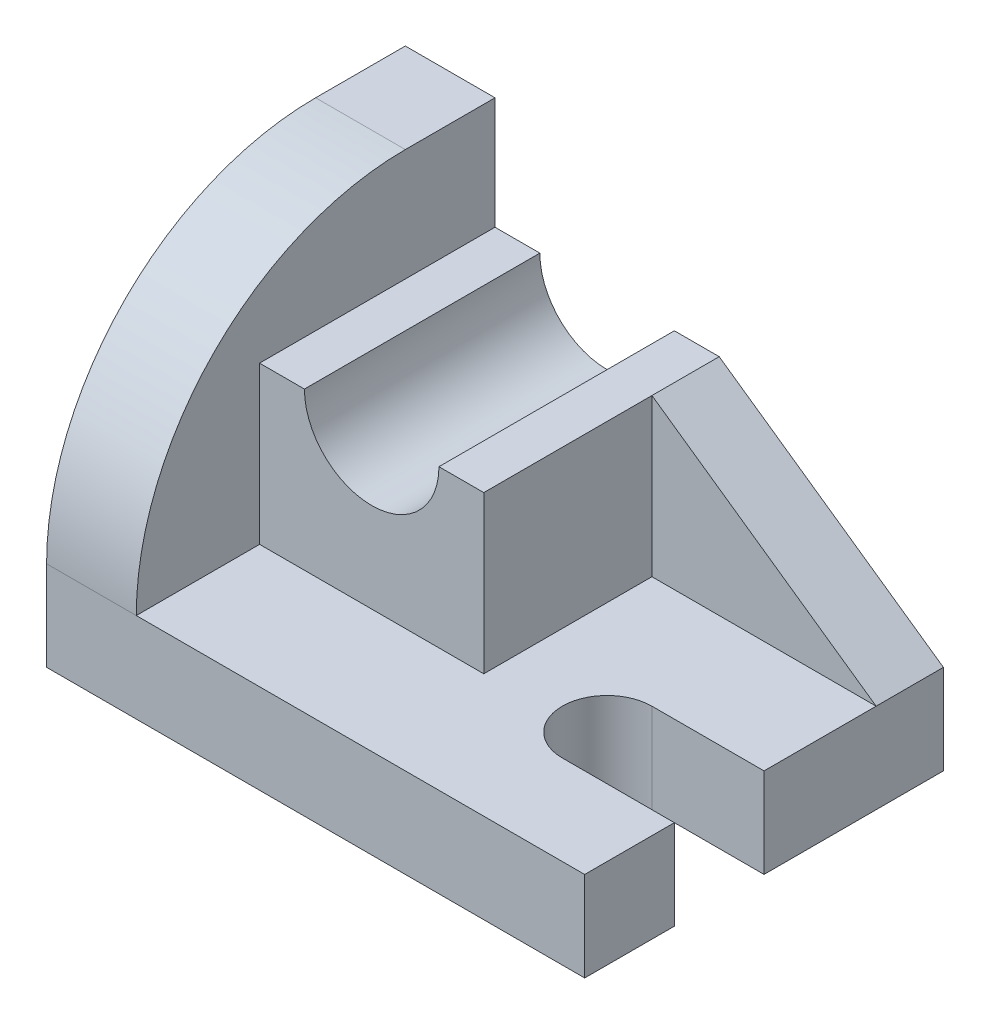
from build123d import *

# Parameters (mm, degrees)
SKETCH1_W           = 96
SKETCH1_H           = 64
BOSS_EXTRUDE1_DEPTH = 16
CUT_EXTRUDE1_DEPTH  = 16
BOSS_EXTRUDE2_DEPTH = 16
SKETCH4_W           = 40
SKETCH4_H           = 42
BOSS_EXTRUDE3_DEPTH = 28
CUT_EXTRUDE2_REACH  = 44
SKETCH5_R           = 12
BOSS_EXTRUDE4_DEPTH = 12


with BuildPart() as part:
    # Sketch1 → Boss-Extrude1 (new body)
    with BuildSketch(Plane(origin=(0, 0, 0), x_dir=(1, 0, 0), z_dir=(0, 1, 0))):
        with Locations((48, 32)):
            Rectangle(SKETCH1_W, SKETCH1_H)
    extrude(amount=BOSS_EXTRUDE1_DEPTH)

    # Sketch2 → Cut-Extrude1 (cut)
    with BuildSketch(Plane(origin=(0, 16, 0), x_dir=(1, 0, 0), z_dir=(0, 1, 0))):
        with BuildLine():
            Line((96, 16), (76, 16))
            ThreePointArc((76, 16), (68, 24), (76, 32))
            Line((76, 32), (96, 32))
            ThreePointArc((96, 32), (104, 24), (96, 16))
        make_face()
    extrude(amount=-CUT_EXTRUDE1_DEPTH, mode=Mode.SUBTRACT)

    # Sketch3 → Boss-Extrude2 (add)
    with BuildSketch(Plane.ZY):
        with BuildLine():
            Line((-64, 0), (0, 0))
            Line((0, 0), (0, 16))
            ThreePointArc((0, 16), (-14.058874503, 49.941125497), (-48, 64))
            Line((-48, 64), (-64, 64))
            Line((-64, 64), (-64, 0))
        make_face()
    extrude(amount=-BOSS_EXTRUDE2_DEPTH)

    # Sketch4 → Boss-Extrude3 (add)
    with BuildSketch(Plane(origin=(0, 16, 0), x_dir=(1, 0, 0), z_dir=(0, 1, 0))):
        with Locations((36, 43)):
            Rectangle(SKETCH4_W, SKETCH4_H)
    extrude(amount=BOSS_EXTRUDE3_DEPTH)

    # Sketch5 → Cut-Extrude2 (cut, up to next)
    with BuildSketch(Plane.XY.offset(-22), mode=Mode.PRIVATE) as cut_extrude2_sk1:
        with Locations((36, 44)):
            Circle(SKETCH5_R)
    cut_extrude2_tool1 = extrude(cut_extrude2_sk1.sketch, amount=-CUT_EXTRUDE2_REACH, mode=Mode.PRIVATE) & part.part
    add(cut_extrude2_tool1.solids().sort_by_distance((36, 44, -22))[0], mode=Mode.SUBTRACT)

    # Sketch7 → Boss-Extrude4 (add)
    with BuildSketch(Plane(origin=(0, 0, -64), x_dir=(-1, 0, 0), z_dir=(0, 0, -1))):
        Polygon((-56, 44), (-96, 16), (-56, 16), align=None)
    extrude(amount=-BOSS_EXTRUDE4_DEPTH)


solid = part.part
